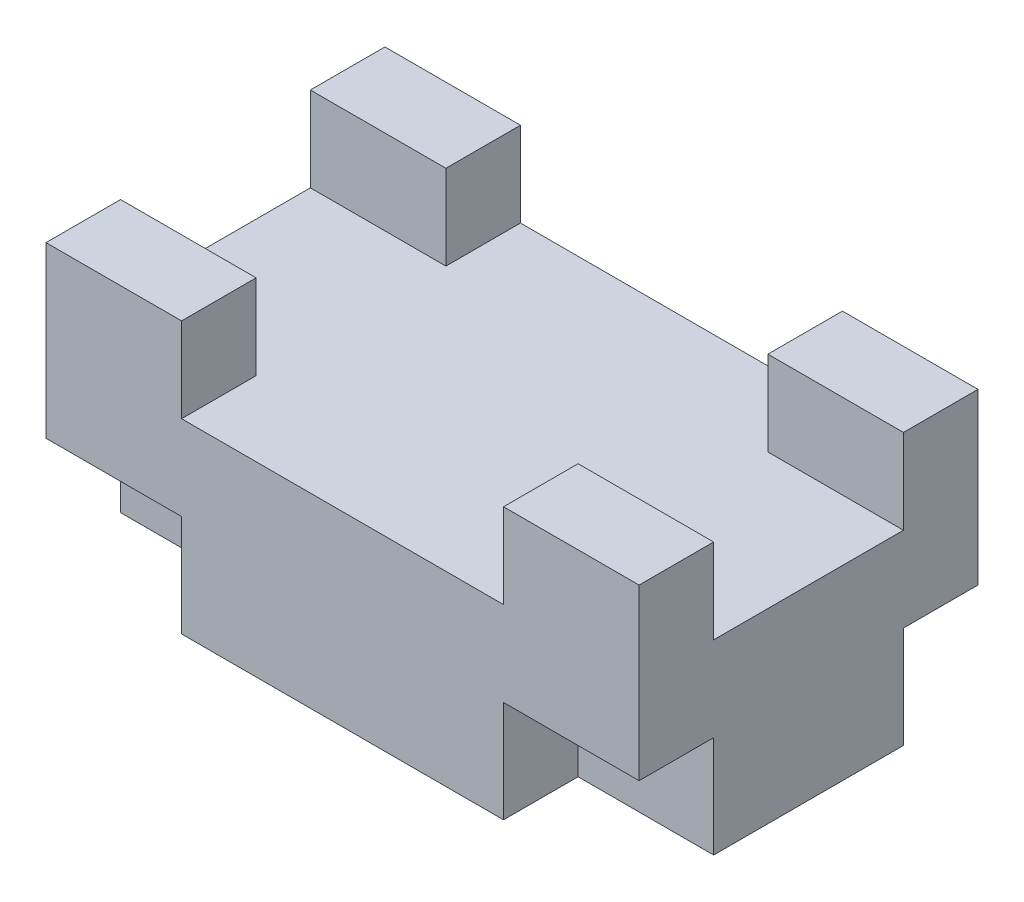
from build123d import *

# Parameters (mm, degrees)
SKETCH1_W           = 175
SKETCH1_H           = 100
BOSS_EXTRUDE1_DEPTH = 80
SKETCH2_W           = 95
SKETCH2_H           = 25
CUT_EXTRUDE1_DEPTH  = 101
SKETCH3_W           = 56
SKETCH3_H           = 25
CUT_EXTRUDE2_DEPTH  = 176
SKETCH4_W           = 40
SKETCH4_H           = 30
CUT_EXTRUDE3_DEPTH  = 22


with BuildPart() as part:
    # Sketch1 → Boss-Extrude1 (new body)
    with BuildSketch(Plane(origin=(0, 0, 0), x_dir=(1, 0, 0), z_dir=(0, 1, 0))):
        Rectangle(SKETCH1_W, SKETCH1_H)
    extrude(amount=BOSS_EXTRUDE1_DEPTH)

    # Sketch2 → Cut-Extrude1 (cut, through all)
    with BuildSketch(Plane.XY.offset(50)):
        with Locations((0, 67.5)):
            Rectangle(SKETCH2_W, SKETCH2_H)
    extrude(amount=-CUT_EXTRUDE1_DEPTH, mode=Mode.SUBTRACT)

    # Sketch3 → Cut-Extrude2 (cut, through all)
    with BuildSketch(Plane(origin=(87.5, 0, 0), x_dir=(0, 0, -1), z_dir=(1, 0, 0))):
        with Locations((0, 67.5)):
            Rectangle(SKETCH3_W, SKETCH3_H)
    extrude(amount=-CUT_EXTRUDE2_DEPTH, mode=Mode.SUBTRACT)

    # Sketch4 → Cut-Extrude3 (cut)
    with BuildSketch(Plane.XY.offset(50)):
        with Locations((-67.5, 15)):
            Rectangle(SKETCH4_W, SKETCH4_H)
        with Locations((67.5, 15)):
            Rectangle(SKETCH4_W, SKETCH4_H)
    cut_extrude3 = extrude(amount=-CUT_EXTRUDE3_DEPTH, mode=Mode.SUBTRACT)

    # Mirror1: Cut-Extrude3 across plane
    add(cut_extrude3.mirror(Plane.XY), mode=Mode.SUBTRACT)


solid = part.part
